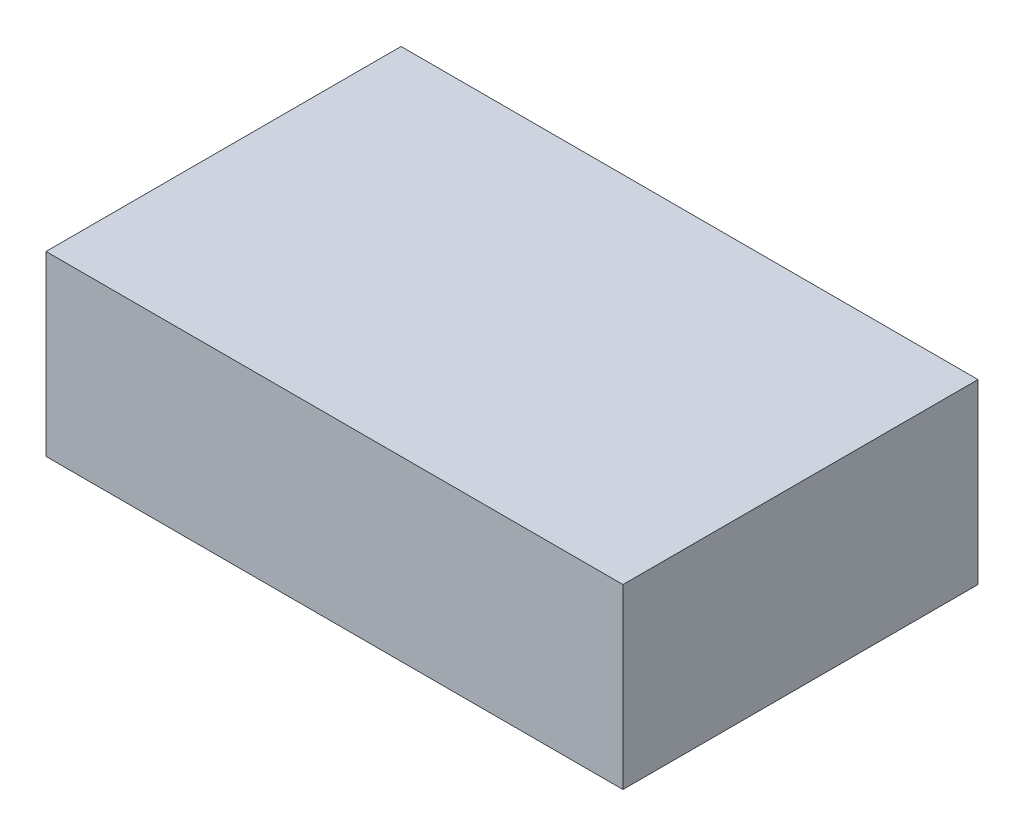
from build123d import *

# Parameters (mm, degrees)
SKETCH1_W           = 2.6
SKETCH1_H           = 1.6
BOSS_EXTRUDE1_DEPTH = 0.8


with BuildPart() as part:
    # Sketch1 → Boss-Extrude1 (new body)
    with BuildSketch(Plane(origin=(0, 0, 0), x_dir=(1, 0, 0), z_dir=(0, 1, 0))):
        with Locations((1.3, 0.8)):
            Rectangle(SKETCH1_W, SKETCH1_H)
    extrude(amount=BOSS_EXTRUDE1_DEPTH)


solid = part.part
